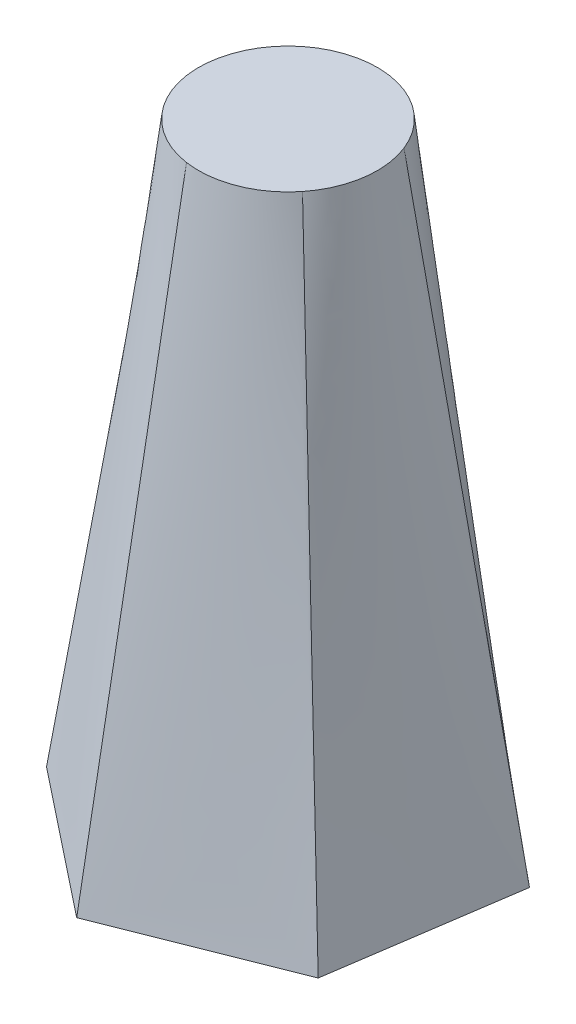
from build123d import *


with BuildPart() as part:
    # Sketch1 → Loft1 section 0
    with BuildSketch(Plane(origin=(0, 0, 0), x_dir=(1, 0, 0), z_dir=(0, 1, 0))):
        Polygon((28.214375639, 11.163079057), (4.439677771, 30.015905584), (-23.774697867, 18.852826527), (-28.214375639, -11.163079057), (-4.439677771, -30.015905584), (23.774697867, -18.852826527), align=None)
    # Sketch2 for Loft1 → Loft1 section 1
    with BuildSketch(Plane(origin=(0, 100, 0), x_dir=(1, 0, 0), z_dir=(0, 1, 0))):
        with BuildLine():
            # circular arc as an exact rational Bezier (weights 1, cos(half-angle), 1)
            Bezier((13.556819541, 5.363785123), (10.460036756, 13.190818534), (2.133235594, 14.422442679), weights=[1, 0.866025404, 1])
            Bezier((2.133235594, 14.422442679), (-6.193565569, 15.654066823), (-11.423583947, 9.058657556), weights=[1, 0.866025404, 1])
            Bezier((-11.423583947, 9.058657556), (-16.653602327, 2.463248289), (-13.556819541, -5.363785123), weights=[1, 0.866025404, 1])
            Bezier((-13.556819541, -5.363785123), (-10.460036756, -13.190818534), (-2.133235594, -14.422442679), weights=[1, 0.866025404, 1])
            Bezier((-2.133235594, -14.422442679), (6.193565569, -15.654066823), (11.423583947, -9.058657556), weights=[1, 0.866025404, 1])
            Bezier((11.423583947, -9.058657556), (16.653602327, -2.463248289), (13.556819541, 5.363785123), weights=[1, 0.866025404, 1])
        make_face()
    loft()


solid = part.part
